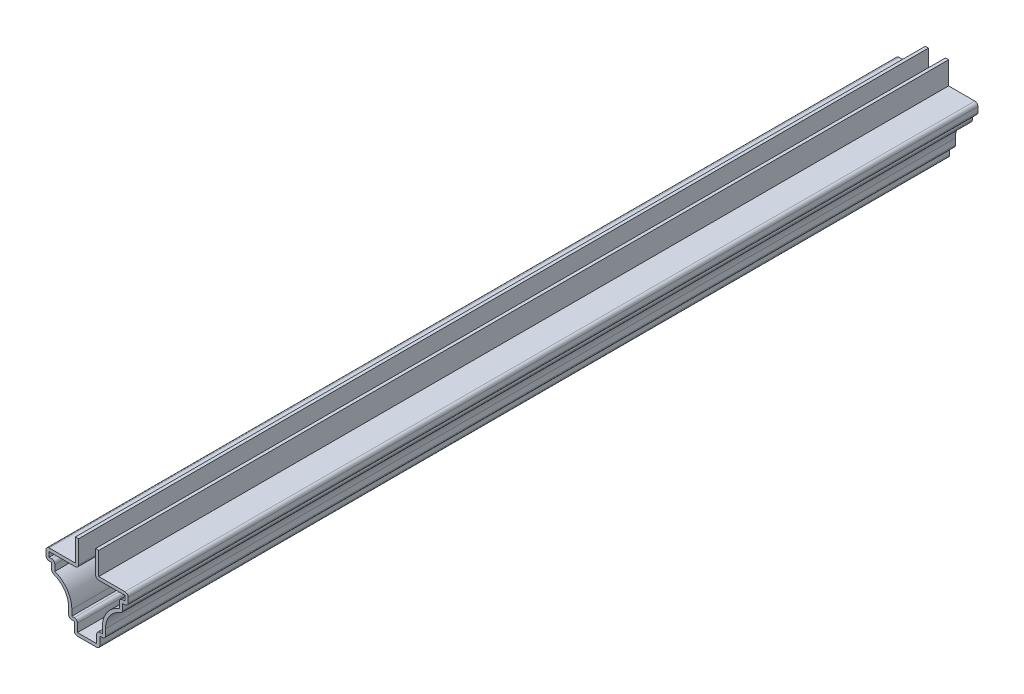
from build123d import *

# Parameters (mm, degrees)
EXTRUDE_THIN1_DEPTH = 238.125
FILLET1_R           = 0.889


with BuildPart() as part:
    # Sketch1 → Extrude-Thin1 (new body)
    with BuildSketch(Plane.XY):
        with BuildLine():
            Line((3.27025, 23.8125), (3.27025, 17.4625))
            Line((3.27025, 17.4625), (11.509375, 17.4625))
            Line((11.509375, 17.4625), (11.509375, 14.2875))
            Line((11.509375, 14.2875), (9.921875, 14.2875))
            Line((9.921875, 14.2875), (9.921875, 11.90625))
            ThreePointArc((9.921875, 11.90625), (6.489259214, 9.646453905), (5.159375, 5.757888938))
            Line((5.159375, 5.757888938), (5.159375, 3.175))
            Line((5.159375, 3.175), (3.571875, 3.175))
            Line((3.571875, 3.175), (3.571875, 0))
            Line((3.571875, 0), (-3.571875, 0))
            Line((-3.571875, 0), (-3.571875, 3.175))
            Line((-3.571875, 3.175), (-5.159375, 3.175))
            Line((-5.159375, 3.175), (-5.159375, 5.757888938))
            ThreePointArc((-5.159375, 5.757888938), (-6.489259214, 9.646453905), (-9.921875, 11.90625))
            Line((-9.921875, 11.90625), (-9.921875, 14.2875))
            Line((-9.921875, 14.2875), (-11.509375, 14.2875))
            Line((-11.509375, 14.2875), (-11.509375, 17.4625))
            Line((-11.509375, 17.4625), (-3.27025, 17.4625))
            Line((-3.27025, 17.4625), (-3.27025, 23.8125))
            Line((-3.27025, 23.8125), (-2.38125, 23.8125))
            Line((-2.38125, 23.8125), (-2.38125, 16.5735))
            Line((-2.38125, 16.5735), (-10.620375, 16.5735))
            Line((-10.620375, 16.5735), (-10.620375, 15.1765))
            Line((-10.620375, 15.1765), (-9.032875, 15.1765))
            Line((-9.032875, 15.1765), (-9.032875, 12.560099516))
            ThreePointArc((-9.032875, 12.560099516), (-5.579345299, 9.909740182), (-4.270375, 5.757888938))
            Line((-4.270375, 5.757888938), (-4.270375, 4.064))
            Line((-4.270375, 4.064), (-2.682875, 4.064))
            Line((-2.682875, 4.064), (-2.682875, 0.889))
            Line((-2.682875, 0.889), (2.682875, 0.889))
            Line((2.682875, 0.889), (2.682875, 4.064))
            Line((2.682875, 4.064), (4.270375, 4.064))
            Line((4.270375, 4.064), (4.270375, 5.757888938))
            ThreePointArc((4.270375, 5.757888938), (5.579345299, 9.909740182), (9.032875, 12.560099516))
            Line((9.032875, 12.560099516), (9.032875, 15.1765))
            Line((9.032875, 15.1765), (10.620375, 15.1765))
            Line((10.620375, 15.1765), (10.620375, 16.5735))
            Line((10.620375, 16.5735), (2.38125, 16.5735))
            Line((2.38125, 16.5735), (2.38125, 23.8125))
            Line((2.38125, 23.8125), (3.27025, 23.8125))
        make_face()
    extrude(amount=-EXTRUDE_THIN1_DEPTH)

    # Fillet1
    fillet1_edges = [part.edges().sort_by_distance(p)[0] for p in [
        (11.509375, 17.4625, -119.0625),
        (11.509375, 14.2875, -119.0625),
        (9.921875, 11.90625, -119.0625),
        (5.159375, 3.175, -119.0625),
        (3.571875, 0, -119.0625),
        (-3.571875, 0, -119.0625),
        (-5.159375, 3.175, -119.0625),
        (-9.921875, 11.90625, -119.0625),
        (-11.509375, 14.2875, -119.0625),
        (-11.509375, 17.4625, -119.0625),
        (-2.38125, 16.5735, -119.0625),
        (-9.032875, 15.1765, -119.0625),
        (-2.682875, 4.064, -119.0625),
        (2.682875, 4.064, -119.0625),
        (9.032875, 15.1765, -119.0625),
        (2.38125, 16.5735, -119.0625),
    ]]
    fillet(fillet1_edges, radius=FILLET1_R)


solid = part.part
